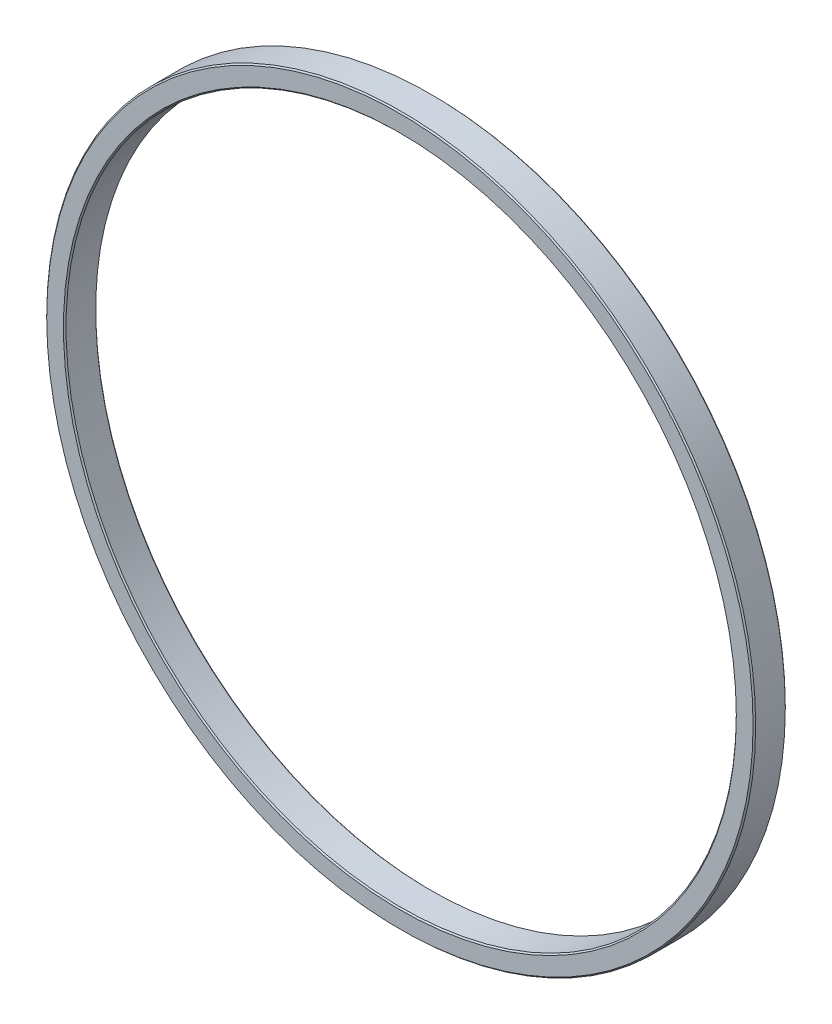
from build123d import *

# Parameters (mm, degrees)
SCHIZZO1_R                   = 55
SCHIZZO1_R_2                 = 52
ESTRUSIONE_ESTRUSIONE1_DEPTH = 5
SMUSSO1_SIZE                 = 0.2


with BuildPart() as part:
    # Schizzo1 → Estrusione-Estrusione1 (new body)
    with BuildSketch(Plane.XY):
        Circle(SCHIZZO1_R)
        Circle(SCHIZZO1_R_2, mode=Mode.SUBTRACT)
    extrude(amount=ESTRUSIONE_ESTRUSIONE1_DEPTH)

    # Smusso1
    smusso1_edges = [part.edges().sort_by_distance(p)[0] for p in [
        (-55, 0, 0),
        (-55, 0, 5),
        (-52, 0, 0),
        (-52, 0, 5),
    ]]
    chamfer(smusso1_edges, length=SMUSSO1_SIZE)


solid = part.part
